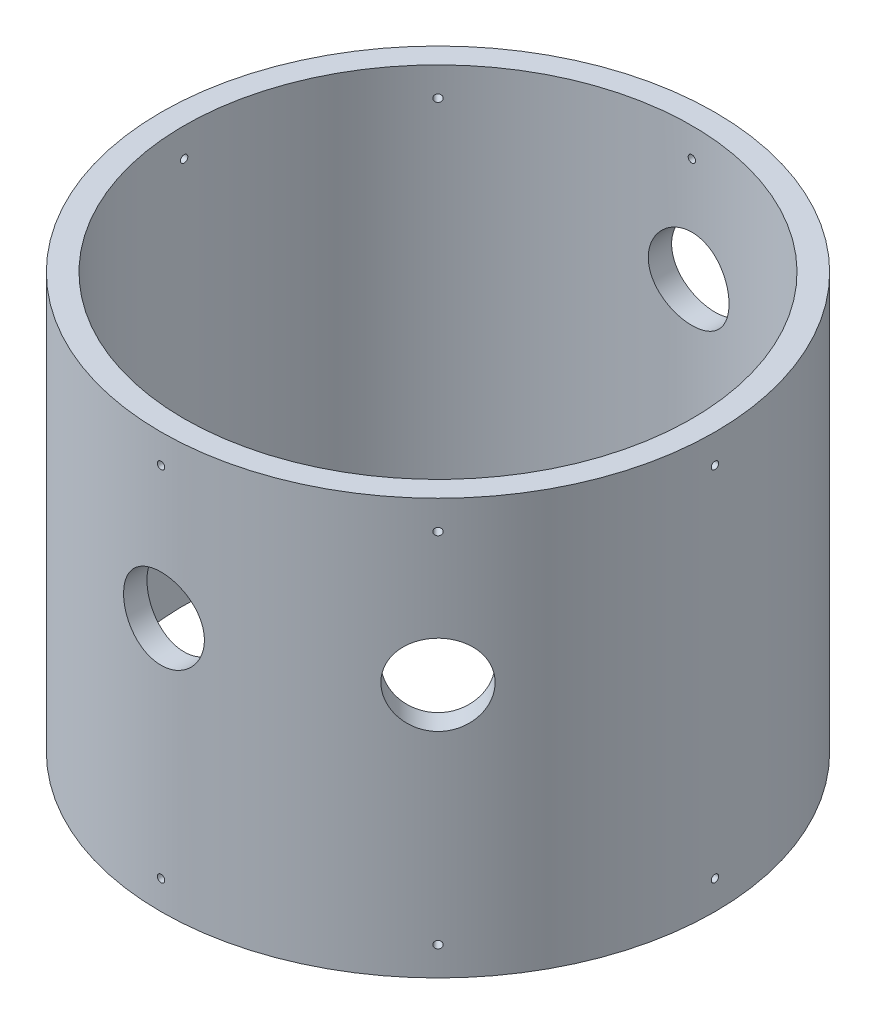
from build123d import *

# Parameters (mm, degrees)
SKETCH1_R                   = 152.4
SKETCH1_R_2                 = 139.7
BOSS_EXTRUDE1_DEPTH         = 228.6
F_10_32_TAPPED_HOLE1_REACH  = 412.35
F_10_32_TAPPED_HOLE1_BORE_R = 2.0193
CIRPATTERN1_COUNT           = 8
PRESSURE_RELIEF_HOLE_REACH  = 412.35
PRESSURE_RELIEF_HOLE_BORE_R = 22.225
HELIUM_IN_REACH             = 435.16
HELIUM_IN_BORE_R            = 22.225
VENT_VALVE_D                = 44.45
VENT_VALVE_DEPTH            = 25.4


with BuildPart() as part:
    # Sketch1 → Boss-Extrude1 (new body)
    with BuildSketch(Plane(origin=(0, 0, 0), x_dir=(1, 0, 0), z_dir=(0, 1, 0))):
        with Locations(Location((0, 0, 0), (0, 0, 270))):
            Circle(SKETCH1_R)
        with Locations(Location((0, 0, 0), (0, 0, 270))):
            Circle(SKETCH1_R_2, mode=Mode.SUBTRACT)
    extrude(amount=BOSS_EXTRUDE1_DEPTH)

    # #10-32 Tapped Hole1 bore → #10-32 Tapped Hole1 (cut, up to next)
    with BuildSketch(Plane.XY.offset(152.4), mode=Mode.PRIVATE) as f_10_32_tapped_hole1_sk1:
        with Locations((0, 212.725)):
            Circle(F_10_32_TAPPED_HOLE1_BORE_R)
    f_10_32_tapped_hole1_tool1 = extrude(f_10_32_tapped_hole1_sk1.sketch, amount=-F_10_32_TAPPED_HOLE1_REACH, mode=Mode.PRIVATE) & part.part
    # #10-32 Tapped Hole1 bore → #10-32 Tapped Hole1 (cut, up to next)
    with BuildSketch(Plane.XY.offset(152.4), mode=Mode.PRIVATE) as f_10_32_tapped_hole1_sk2:
        with Locations((0, 15.875)):
            Circle(F_10_32_TAPPED_HOLE1_BORE_R)
    f_10_32_tapped_hole1_tool2 = extrude(f_10_32_tapped_hole1_sk2.sketch, amount=-F_10_32_TAPPED_HOLE1_REACH, mode=Mode.PRIVATE) & part.part
    f_10_32_tapped_hole1_1 = f_10_32_tapped_hole1_tool1.solids().sort_by_distance((0, 212.725, 152.4))[0]
    add(f_10_32_tapped_hole1_1, mode=Mode.SUBTRACT)
    f_10_32_tapped_hole1_2 = f_10_32_tapped_hole1_tool2.solids().sort_by_distance((0, 15.875, 152.4))[0]
    add(f_10_32_tapped_hole1_2, mode=Mode.SUBTRACT)
    f_10_32_tapped_hole1 = f_10_32_tapped_hole1_1 + f_10_32_tapped_hole1_2  # #10-32 Tapped Hole1 as one shape, for the pattern or mirror that repeats it

    # CirPattern1: #10-32 Tapped Hole1 ×8 about axis
    cirpattern1_axis = Axis((0, 228.6, 0), (0, 1, 0))
    for i in range(1, CIRPATTERN1_COUNT):
        add(f_10_32_tapped_hole1.rotate(cirpattern1_axis, i * 360 / CIRPATTERN1_COUNT), mode=Mode.SUBTRACT)

    # Pressure Relief Hole bore → Pressure Relief Hole (cut, up to next)
    with BuildSketch(Plane.XY.offset(152.4), mode=Mode.PRIVATE) as pressure_relief_hole_sk1:
        with Locations((0, 139.7)):
            Circle(PRESSURE_RELIEF_HOLE_BORE_R)
    pressure_relief_hole_tool1 = extrude(pressure_relief_hole_sk1.sketch, amount=-PRESSURE_RELIEF_HOLE_REACH, mode=Mode.PRIVATE) & part.part
    add(pressure_relief_hole_tool1.solids().sort_by_distance((0, 139.7, 152.4))[0], mode=Mode.SUBTRACT)

    # Helium In bore → Helium In (cut, up to next)
    with BuildSketch(Plane(origin=(107.763073453, 0, 107.763073453), x_dir=(0, -1, 0), z_dir=(0.7071067811865488, 0, 0.7071067811865464)), mode=Mode.PRIVATE) as helium_in_sk1:
        with Locations((-139.7, 0)):
            Circle(HELIUM_IN_BORE_R)
    helium_in_tool1 = extrude(helium_in_sk1.sketch, amount=-HELIUM_IN_REACH, mode=Mode.PRIVATE) & part.part
    add(helium_in_tool1.solids().sort_by_distance((107.763073, 139.7, 107.763073))[0], mode=Mode.SUBTRACT)

    # Vent Valve
    with Locations(Plane(origin=(0, 0, -152.4), x_dir=(-1, 0, 0), z_dir=(0, 0, -1))):
        with Locations((0, 155.575)):
            Hole(VENT_VALVE_D / 2, depth=VENT_VALVE_DEPTH)


solid = part.part
